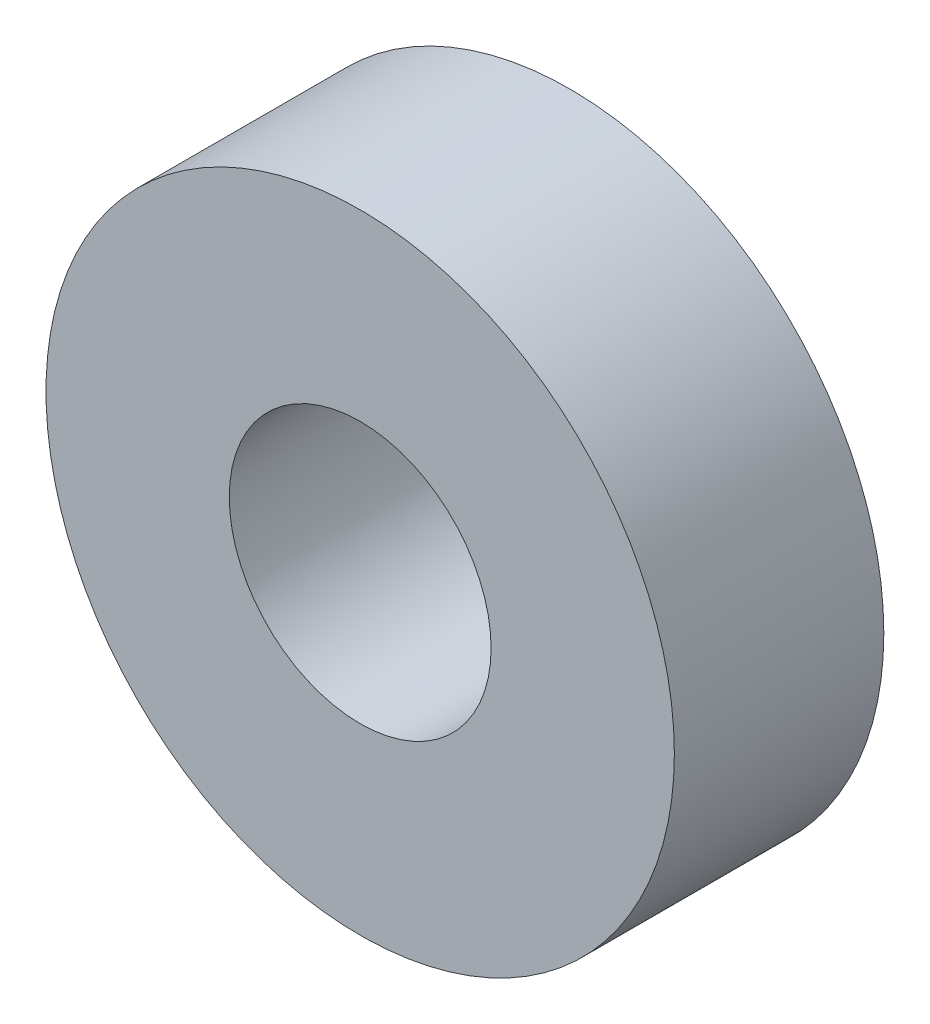
from build123d import *

# Parameters (mm, degrees)
ESBO_O1_R                = 6
ESBO_O1_R_2              = 2.5
RESSALTO_EXTRUS_O1_DEPTH = 4


with BuildPart() as part:
    # Esboço1 → Ressalto-extrusão1 (new body)
    with BuildSketch(Plane.XY):
        Circle(ESBO_O1_R)
        Circle(ESBO_O1_R_2, mode=Mode.SUBTRACT)
    extrude(amount=RESSALTO_EXTRUS_O1_DEPTH)


solid = part.part
